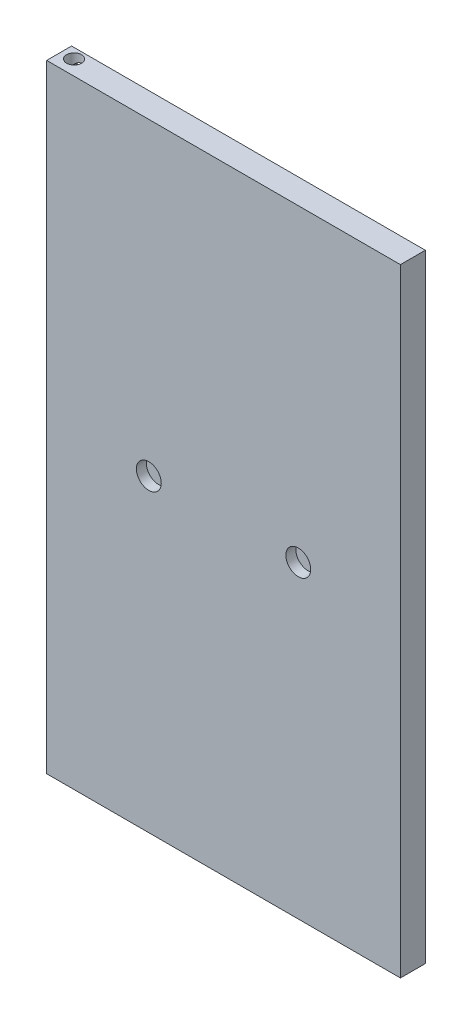
from build123d import *

# Parameters (mm, degrees)
SKETCH1_W           = 180.34
SKETCH1_H           = 314.96
BOSS_EXTRUDE1_DEPTH = 12.7
SKETCH4_R           = 6.35
CUT_EXTRUDE2_DEPTH  = 5.08
SKETCH6_R           = 3.81
CUT_EXTRUDE3_DEPTH  = 5.08
SKETCH7_R           = 3.81
CUT_EXTRUDE4_DEPTH  = 7.62
SKETCH8_R           = 3.81
CUT_EXTRUDE5_DEPTH  = 7.62


with BuildPart() as part:
    # Sketch1 → Boss-Extrude1 (new body)
    with BuildSketch(Plane.XY):
        Rectangle(SKETCH1_W, SKETCH1_H)
    extrude(amount=-BOSS_EXTRUDE1_DEPTH)

    # Sketch4 → Cut-Extrude2 (cut)
    with BuildSketch(Plane.XY):
        with Locations((-38.1, 0)):
            Circle(SKETCH4_R)
        with Locations((38.1, 0)):
            Circle(SKETCH4_R)
    extrude(amount=-CUT_EXTRUDE2_DEPTH, mode=Mode.SUBTRACT)

    # Sketch6 → Cut-Extrude3 (cut)
    with BuildSketch(Plane(origin=(0, 0, -12.7), x_dir=(-1, 0, 0), z_dir=(0, 0, -1))):
        with Locations((83.759872632, 149.86)):
            Circle(SKETCH6_R)
        with Locations((83.82, -149.86)):
            Circle(SKETCH6_R)
    extrude(amount=-CUT_EXTRUDE3_DEPTH, mode=Mode.SUBTRACT)

    # Sketch7 → Cut-Extrude4 (cut)
    with BuildSketch(Plane(origin=(0, 157.48, 0), x_dir=(1, 0, 0), z_dir=(0, 1, 0))):
        with Locations((-83.82, 7.62)):
            Circle(SKETCH7_R)
    extrude(amount=-CUT_EXTRUDE4_DEPTH, mode=Mode.SUBTRACT)

    # Sketch8 → Cut-Extrude5 (cut)
    with BuildSketch(Plane(origin=(0, -157.48, 0), x_dir=(-1, 0, 0), z_dir=(0, -1, 0))):
        with Locations((83.82, 7.62)):
            Circle(SKETCH8_R)
    extrude(amount=-CUT_EXTRUDE5_DEPTH, mode=Mode.SUBTRACT)


solid = part.part
